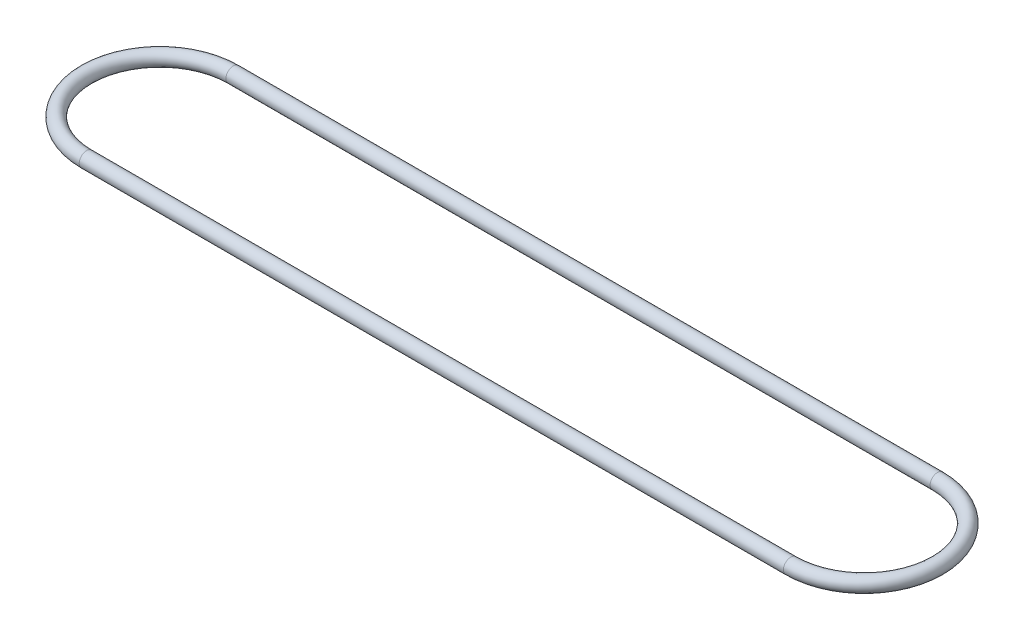
from build123d import *

# Parameters (mm, degrees)
SKETCH2_R = 3.175


with BuildPart() as part:
    # Sweep1: sweep along a path in Sketch1
    with BuildLine(Plane(origin=(0, 0, 0), x_dir=(1, 0, 0), z_dir=(0, 1, 0))) as sweep1_path:
        Line((0, 0), (304.8, 0))
        ThreePointArc((304.8, 0), (336.55, 31.75), (304.8, 63.5))
        Line((304.8, 63.5), (0, 63.5))
        ThreePointArc((0, 63.5), (-31.75, 31.75), (0, 0))
    # Sketch2 → Sweep1 (sweep)
    with BuildSketch(Plane(origin=(0, 0, 0), x_dir=(0, 0, -1), z_dir=(1, 0, 0))):
        Circle(SKETCH2_R)
    sweep(path=sweep1_path.line)


solid = part.part
